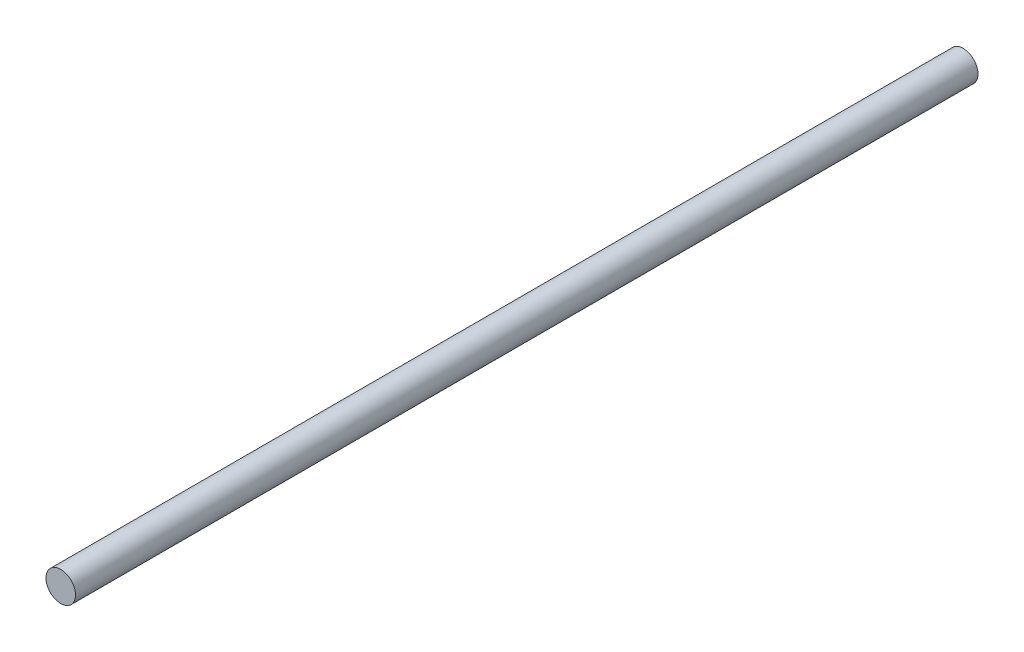
from build123d import *

# Parameters (mm, degrees)
SKETCH1_R           = 0.5
BOSS_EXTRUDE1_DEPTH = 30.5


with BuildPart() as part:
    # Sketch1 → Boss-Extrude1 (new body)
    with BuildSketch(Plane.XY):
        Circle(SKETCH1_R)
    extrude(amount=BOSS_EXTRUDE1_DEPTH)


solid = part.part
